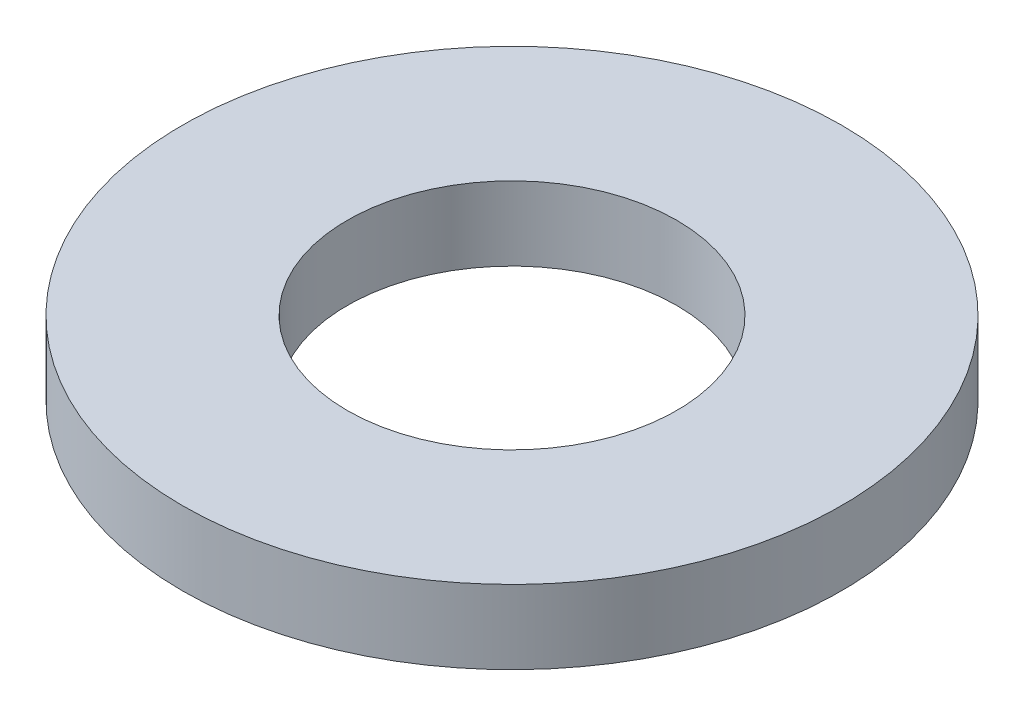
from build123d import *

# Parameters (mm, degrees)
SKETCH1_R           = 3.175
BOSS_EXTRUDE1_DEPTH = 0.7112
SKETCH5_R           = 1.5875
CUT_EXTRUDE1_DEPTH  = 1.7112


with BuildPart() as part:
    # Sketch1 → Boss-Extrude1 (new body)
    with BuildSketch(Plane(origin=(0, 0, 0), x_dir=(1, 0, 0), z_dir=(0, 1, 0))):
        Circle(SKETCH1_R)
    extrude(amount=BOSS_EXTRUDE1_DEPTH)

    # Sketch5 → Cut-Extrude1 (cut, through all)
    with BuildSketch(Plane(origin=(0, 0.7112, 0), x_dir=(-1, 0, 0), z_dir=(0, 1, 0))):
        Circle(SKETCH5_R)
    extrude(amount=-CUT_EXTRUDE1_DEPTH, mode=Mode.SUBTRACT)


solid = part.part
